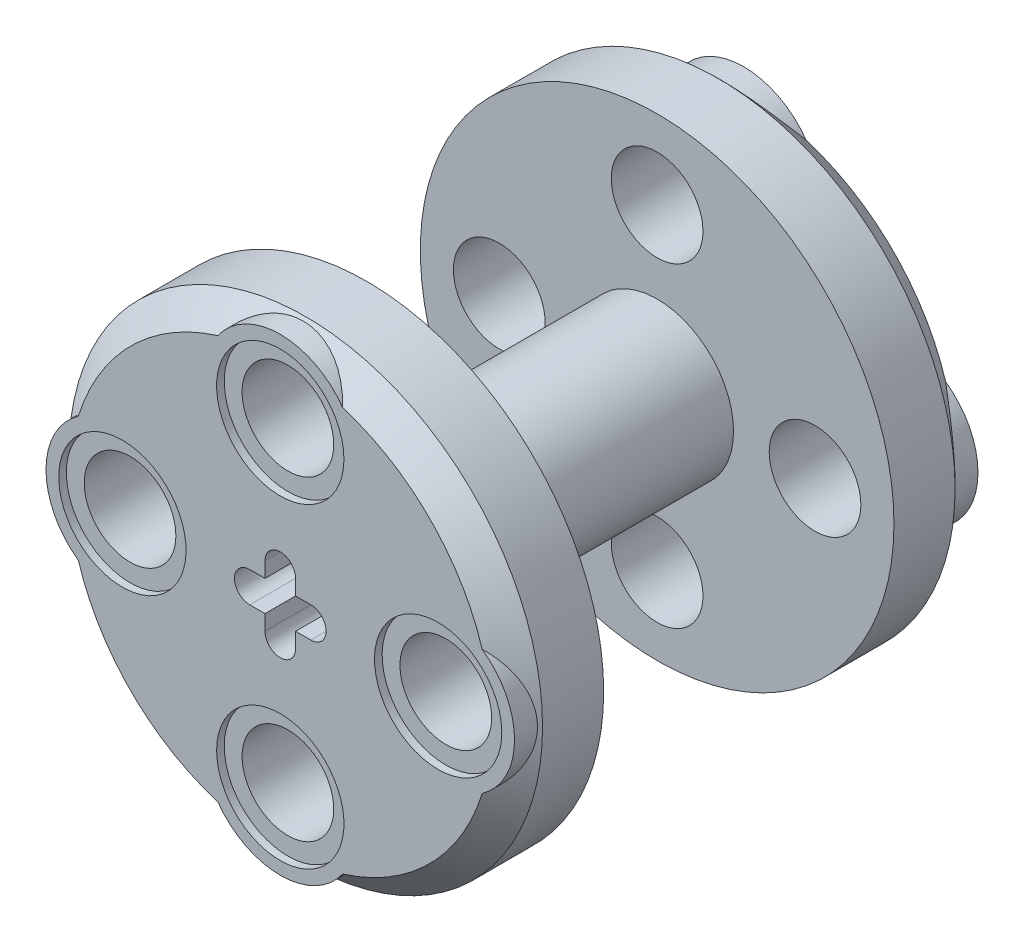
from build123d import *

# Parameters (mm, degrees)
SKETCH1_R           = 11.811
SKETCH1_R_2         = 2.286
EXTRUDE1_DEPTH      = 4.318
CHAMFER1_SIZE       = 1.27
SKETCH2_R           = 2.794
SKETCH2_R_2         = 2.306678084
SKETCH2_R_3         = 2.286
SKETCH2_R_4         = 2.290860138
EXTRUDE2_DEPTH      = 4.318
SKETCH3_R           = 3.81
EXTRUDE3_DEPTH      = 7.239
SKETCH4_W           = 1.524
SKETCH4_H           = 1.524
CUT_EXTRUDE1_DEPTH  = 12.557
SKETCH5_R           = 3.81
SKETCH5_R_2         = 2.286
BOSS_EXTRUDE3_DEPTH = 4.318
SKETCH6_R           = 3.81
SKETCH6_R_2         = 2.286
BOSS_EXTRUDE5_DEPTH = 4.318
SKETCH5_3_R         = 3.175
CUT_EXTRUDE2_DEPTH  = 0.381
SKETCH6_3_R         = 3.175
CUT_EXTRUDE3_DEPTH  = 0.381
CIRPATTERN1_COUNT   = 4


with BuildPart() as part:
    # Sketch1 → Extrude1 (new body)
    with BuildSketch(Plane.XY):
        Circle(SKETCH1_R)
        with Locations((0, 7.874)):
            Circle(SKETCH1_R_2, mode=Mode.SUBTRACT)
        with Locations((7.874, 0)):
            Circle(SKETCH1_R_2, mode=Mode.SUBTRACT)
        with Locations((0, -7.874)):
            Circle(SKETCH1_R_2, mode=Mode.SUBTRACT)
        with Locations((-7.874, 0)):
            Circle(SKETCH1_R_2, mode=Mode.SUBTRACT)
    extrude(amount=EXTRUDE1_DEPTH)

    # Chamfer1
    chamfer1_edges = [part.edges().sort_by_distance(p)[0] for p in [
        (-11.811, 0, 4.318),
    ]]
    chamfer(chamfer1_edges, length=CHAMFER1_SIZE)

    # Sketch2 → Extrude2 (add)
    with BuildSketch(Plane.XY.offset(4.318)):
        with Locations((0, 7.874)):
            Circle(SKETCH2_R)
        with Locations((0, 7.874)):
            Circle(SKETCH2_R_2, mode=Mode.SUBTRACT)
        with Locations((-7.874, 0)):
            Circle(SKETCH2_R)
        with Locations((-7.874, 0)):
            Circle(SKETCH2_R_3, mode=Mode.SUBTRACT)
        with Locations((0, -7.874)):
            Circle(SKETCH2_R)
        with Locations((0, -7.874)):
            Circle(SKETCH2_R_4, mode=Mode.SUBTRACT)
        with Locations((7.874, 0)):
            Circle(SKETCH2_R)
        with Locations((7.874, 0)):
            Circle(SKETCH2_R_3, mode=Mode.SUBTRACT)
    extrude(amount=-EXTRUDE2_DEPTH)

    # Sketch3 → Extrude3 (add)
    with BuildSketch(Plane(origin=(0, 0, 0), x_dir=(-1, 0, 0), z_dir=(0, 0, -1))):
        Circle(SKETCH3_R)
    extrude(amount=EXTRUDE3_DEPTH)

    # Sketch4 → Cut-Extrude1 (cut, through all)
    with BuildSketch(Plane.XY.offset(4.318)):
        with BuildLine():
            Line((-0.762, 0.762), (-1.524, 0.762))
            ThreePointArc((-1.524, 0.762), (-2.286, 0), (-1.524, -0.762))
            Line((-1.524, -0.762), (-0.762, -0.762))
            Line((-0.762, -0.762), (-0.762, 0.762))
        make_face()
        with BuildLine():
            Line((-0.762, 1.524), (-0.762, 0.762))
            Line((-0.762, 0.762), (0.762, 0.762))
            Line((0.762, 0.762), (0.762, 1.524))
            ThreePointArc((0.762, 1.524), (0, 2.286), (-0.762, 1.524))
        make_face()
        with BuildLine():
            Line((1.524, 0.762), (0.762, 0.762))
            Line((0.762, 0.762), (0.762, -0.762))
            Line((0.762, -0.762), (1.524, -0.762))
            ThreePointArc((1.524, -0.762), (2.286, 0), (1.524, 0.762))
        make_face()
        Rectangle(SKETCH4_W, SKETCH4_H)
        with BuildLine():
            Line((0.762, -0.762), (-0.762, -0.762))
            Line((-0.762, -0.762), (-0.762, -1.524))
            ThreePointArc((-0.762, -1.524), (0, -2.286), (0.762, -1.524))
            Line((0.762, -1.524), (0.762, -0.762))
        make_face()
    extrude(amount=-CUT_EXTRUDE1_DEPTH, mode=Mode.SUBTRACT)

    # Mirror1: part across plane


with BuildPart() as part_1:
    add(part.part)
    add(part.part.mirror(Plane.XY.offset(-7.239)))

    # Sketch5 → Boss-Extrude3 (add)
    with BuildSketch(Plane.XY.offset(4.318)):
        with Locations((0, 7.874)):
            Circle(SKETCH5_R)
        with Locations((0, 7.874)):
            Circle(SKETCH5_R_2, mode=Mode.SUBTRACT)
    boss_extrude3 = extrude(amount=-BOSS_EXTRUDE3_DEPTH)

    # Sketch6 → Boss-Extrude5 (add)
    with BuildSketch(Plane(origin=(0, 0, -18.796), x_dir=(-1, 0, 0), z_dir=(0, 0, -1))):
        with Locations((0, 7.874)):
            Circle(SKETCH6_R)
        with Locations((0, 7.874)):
            Circle(SKETCH6_R_2, mode=Mode.SUBTRACT)
    boss_extrude5 = extrude(amount=-BOSS_EXTRUDE5_DEPTH)

    # Sketch5_3 → Cut-Extrude2 (cut)
    with BuildSketch(Plane.XY.offset(4.318)):
        with Locations((0, 7.874)):
            Circle(SKETCH5_3_R)
    cut_extrude2 = extrude(amount=-CUT_EXTRUDE2_DEPTH, mode=Mode.SUBTRACT)

    # Sketch6_3 → Cut-Extrude3 (cut)
    with BuildSketch(Plane(origin=(0, 0, -18.796), x_dir=(-1, 0, 0), z_dir=(0, 0, -1))):
        with Locations((0, 7.874)):
            Circle(SKETCH6_3_R)
    cut_extrude3 = extrude(amount=-CUT_EXTRUDE3_DEPTH, mode=Mode.SUBTRACT)

    # CirPattern1: Boss-Extrude3, Boss-Extrude5, Cut-Extrude2, Cut-Extrude3 ×4 about axis
    cirpattern1_axis = Axis((0, 0, 0), (0, 0, 1))
    for i in range(1, CIRPATTERN1_COUNT):
        add(boss_extrude3.rotate(cirpattern1_axis, i * 360 / CIRPATTERN1_COUNT))
        add(boss_extrude5.rotate(cirpattern1_axis, i * 360 / CIRPATTERN1_COUNT))
        add(cut_extrude2.rotate(cirpattern1_axis, i * 360 / CIRPATTERN1_COUNT), mode=Mode.SUBTRACT)
        add(cut_extrude3.rotate(cirpattern1_axis, i * 360 / CIRPATTERN1_COUNT), mode=Mode.SUBTRACT)


solid = part_1.part
